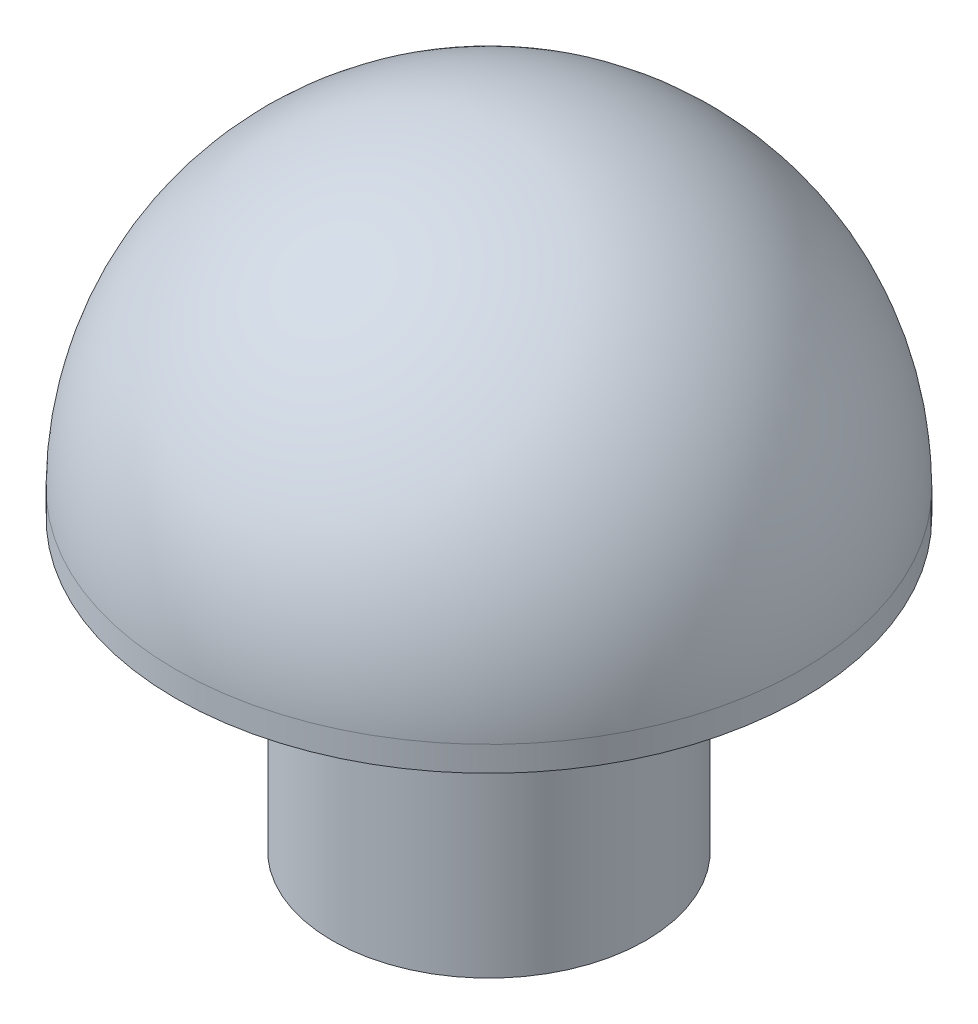
from build123d import *

# Parameters (mm, degrees)
SKETCH1_R           = 2.5
BOSS_EXTRUDE1_DEPTH = 10
SKETCH2_R           = 5
BOSS_EXTRUDE2_DEPTH = 5.4
FILLET1_R           = 5


with BuildPart() as part:
    # Sketch1 → Boss-Extrude1 (new body)
    with BuildSketch(Plane(origin=(0, 0, 0), x_dir=(1, 0, 0), z_dir=(0, 1, 0))):
        Circle(SKETCH1_R)
    extrude(amount=BOSS_EXTRUDE1_DEPTH)

    # Sketch2 → Boss-Extrude2 (add)
    with BuildSketch(Plane(origin=(0, 10, 0), x_dir=(1, 0, 0), z_dir=(0, 1, 0))):
        Circle(SKETCH2_R)
    extrude(amount=-BOSS_EXTRUDE2_DEPTH)

    # Fillet1
    fillet1_edges = [part.edges().sort_by_distance(p)[0] for p in [
        (-5, 10, 0),
    ]]
    fillet(fillet1_edges, radius=FILLET1_R)


solid = part.part
